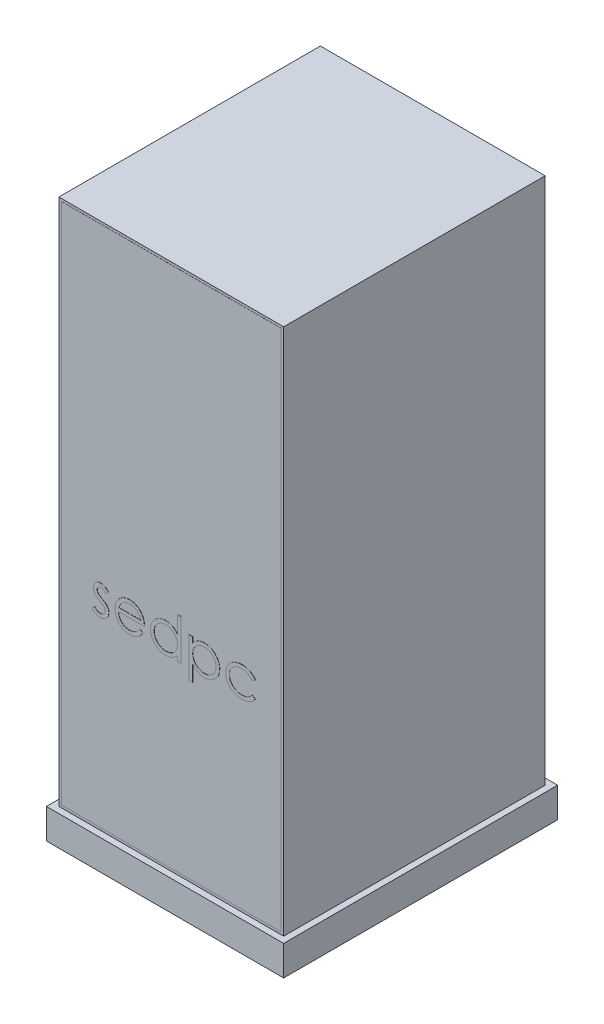
from build123d import *

# Parameters (mm, degrees)
CROQUIS1_W              = 900
CROQUIS1_H              = 2113
SALIENTE_EXTRUIR1_DEPTH = 1047
VACIADO1_T              = -10
CROQUIS9_W              = 880
CROQUIS9_H              = 2093
SALIENTE_EXTRUIR5_DEPTH = 0.3
CORTAR_EXTRUIR5_DEPTH   = 0.2
SALIENTE_EXTRUIR6_DEPTH = 1
CROQUIS15_W             = 950
CROQUIS15_H             = 1097
SALIENTE_EXTRUIR7_DEPTH = 120


with BuildPart() as part:
    # Croquis1 → Saliente-Extruir1 (new body)
    with BuildSketch(Plane.XY):
        Rectangle(CROQUIS1_W, CROQUIS1_H)
    extrude(amount=SALIENTE_EXTRUIR1_DEPTH)

    # Vaciado1
    vaciado1_openings = [part.faces().sort_by_distance(p)[0] for p in [
        (0, 0, 1047),
    ]]
    offset(amount=VACIADO1_T, openings=vaciado1_openings, kind=Kind.INTERSECTION)

    # Croquis15 → Saliente-Extruir7 (add)
    with BuildSketch(Plane.XZ.offset(1056.5)):
        with Locations((0, 523.5)):
            Rectangle(CROQUIS15_W, CROQUIS15_H)
    extrude(amount=SALIENTE_EXTRUIR7_DEPTH)


with BuildPart() as body_2:
    # Croquis9 → Saliente-Extruir5 (new body)
    with BuildSketch(Plane.XY.offset(1047)):
        Rectangle(CROQUIS9_W, CROQUIS9_H)
    extrude(amount=SALIENTE_EXTRUIR5_DEPTH)

    # Croquis10 → Cortar-Extruir5 (cut)
    with BuildSketch(Plane(origin=(0, 0, 1047), x_dir=(-1, 0, 0), z_dir=(0, 0, -1))):
        Polygon((107.980571754, 0), (-99.663574936, 0), (20.123484036, 235.750214308), align=None)
        Polygon((47.696579544, 86.228856266), (21.48645753, 63.632093208), (46.546966911, 34.564256945), (4.587154884, 63.632093208), (27.704744473, 97.00264425), (4.587154884, 113.017451669), (20.123484036, 163.685139928), align=None, mode=Mode.SUBTRACT)
    extrude(amount=-CORTAR_EXTRUIR5_DEPTH, mode=Mode.SUBTRACT)

    # Croquis14 → Saliente-Extruir6 (add)
    with BuildSketch(Plane.XY.offset(1047)):
        with BuildLine():
            Line((-250.963797924, -213.988811505), (-260.631265873, -223.942487386))
            add(Edge.make_bspline(
                [(-260.631265873, -223.942487386), (-261.465406568, -222.975783963), (-263.073531631, -221.112093568), (-265.624030948, -218.620305194), (-268.165101539, -216.527665464), (-270.66195844, -214.760902292), (-273.177387073, -213.425173142), (-275.681868717, -212.450227619), (-278.1779965, -211.846895719), (-279.846505954, -211.769133678), (-280.665821161, -211.730948924)],
                knots=[0, 0, 0, 0, 0.003829333, 0.007382504, 0.010680609, 0.013697506, 0.016542752, 0.019200362, 0.021746022, 0.024202113, 0.024202113, 0.024202113, 0.024202113], degree=3))
            add(Edge.make_bspline(
                [(-280.665821161, -211.730948924), (-281.670000629, -211.779702092), (-283.646083705, -211.875641425), (-286.477540466, -212.833286301), (-289.106015243, -214.303254081), (-291.380992551, -216.388257692), (-293.308112323, -218.781494171), (-294.714804283, -221.457398907), (-295.575047112, -224.33522089), (-295.684118887, -226.332289434), (-295.73943895, -227.345181697)],
                knots=[0, 0, 0, 0, 0.003002953, 0.005909387, 0.008871652, 0.011980015, 0.015103956, 0.018048416, 0.020996994, 0.024031604, 0.024031604, 0.024031604, 0.024031604], degree=3))
            add(Edge.make_bspline(
                [(-295.73943895, -227.345181697), (-295.689055679, -228.261942271), (-295.588431168, -230.092879083), (-294.806171075, -232.793807761), (-293.560388515, -235.427109136), (-292.396061846, -237.04014096), (-291.796129655, -237.871273444)],
                knots=[0, 0, 0, 0, 0.002746683, 0.005485624, 0.008373207, 0.011442609, 0.011442609, 0.011442609, 0.011442609], degree=3))
            add(Edge.make_bspline(
                [(-291.796129655, -237.871273444), (-291.43492833, -238.315074233), (-290.666156835, -239.259648279), (-289.223413477, -240.570644487), (-287.589535669, -242.019453728), (-285.624667064, -243.468017405), (-283.413459728, -244.99345637), (-280.907963623, -246.535695973), (-278.187691433, -248.212296673), (-276.240177883, -249.275669285), (-275.22787044, -249.828404854)],
                knots=[0, 0, 0, 0, 0.001714301, 0.003648673, 0.005835547, 0.008265143, 0.010964286, 0.013893595, 0.017089544, 0.020548977, 0.020548977, 0.020548977, 0.020548977], degree=3))
            add(Edge.make_bspline(
                [(-275.22787044, -249.828404854), (-273.993540336, -250.519870089), (-271.609221015, -251.855553237), (-268.221370501, -253.928814789), (-265.146743999, -255.98945439), (-262.359290503, -258.015434312), (-259.912644173, -260.063439379), (-257.732573392, -262.054969784), (-255.873454685, -264.050199124), (-254.832330153, -265.444165352), (-254.334691354, -266.110456136)],
                knots=[0, 0, 0, 0, 0.004244197, 0.00819839, 0.011911611, 0.015346254, 0.018530315, 0.021478207, 0.02420141, 0.026694891, 0.026694891, 0.026694891, 0.026694891], degree=3))
            add(Edge.make_bspline(
                [(-254.334691354, -266.110456136), (-253.50871386, -267.45602513), (-251.864865351, -270.133957159), (-250.138651122, -274.543507261), (-249.138060085, -279.22030505), (-248.999166525, -282.419445034), (-248.928541514, -284.046153251)],
                knots=[0, 0, 0, 0, 0.004729359, 0.009412302, 0.014127634, 0.019005727, 0.019005727, 0.019005727, 0.019005727], degree=3))
            add(Edge.make_bspline(
                [(-248.928541514, -284.046153251), (-248.961177512, -285.192289527), (-249.025490311, -287.450876265), (-249.472624062, -290.777134612), (-250.241653345, -293.958237758), (-251.289120042, -297.028702457), (-252.703554099, -299.929697218), (-254.361257755, -302.734412797), (-256.351298395, -305.382178229), (-258.623300075, -307.86951678), (-261.11093498, -310.141263181), (-263.764606255, -312.138063946), (-266.587581787, -313.796971383), (-269.55969028, -315.169720971), (-272.687684589, -316.261388385), (-275.972053782, -317.017153195), (-279.402358007, -317.469489145), (-281.735067162, -317.532285029), (-282.923683741, -317.564282258)],
                knots=[0, 0, 0, 0, 0.003438174, 0.006775297, 0.01004569, 0.013243853, 0.016486919, 0.019710123, 0.023004701, 0.026403827, 0.029802953, 0.03309753, 0.036348072, 0.039606382, 0.042905101, 0.046268336, 0.049700032, 0.053265278, 0.053265278, 0.053265278, 0.053265278], degree=3))
            add(Edge.make_bspline(
                [(-282.923683741, -317.564282258), (-284.52783777, -317.519256207), (-287.713856242, -317.42982974), (-292.425997075, -316.59044768), (-297.030688629, -315.284370882), (-301.493084921, -313.482969582), (-305.713390801, -311.208276535), (-309.57468631, -308.484017969), (-313.090384786, -305.400185944), (-315.09146363, -303.036493209), (-316.092003052, -301.854646841)],
                knots=[0, 0, 0, 0, 0.004808668, 0.009550519, 0.014311845, 0.019148298, 0.023957807, 0.028660253, 0.033300349, 0.037940445, 0.037940445, 0.037940445, 0.037940445], degree=3))
            Line((-316.092003052, -301.854646841), (-306.647141273, -291.105948924))
            add(Edge.make_bspline(
                [(-306.647141273, -291.105948924), (-305.750321113, -292.07454003), (-304.011699631, -293.952300342), (-301.231251583, -296.452582937), (-298.401900176, -298.548140591), (-295.551898321, -300.300895477), (-292.639058328, -301.651422691), (-289.679703683, -302.600230344), (-286.679853734, -303.210020491), (-284.664992574, -303.281606868), (-283.655104014, -303.317487386)],
                knots=[0, 0, 0, 0, 0.003958667, 0.007674474, 0.011198064, 0.014508564, 0.0176958, 0.02080335, 0.023815717, 0.026842821, 0.026842821, 0.026842821, 0.026842821], degree=3))
            add(Edge.make_bspline(
                [(-283.655104014, -303.317487386), (-282.279969515, -303.255310687), (-279.593187379, -303.133827847), (-275.744916899, -302.03087403), (-272.191700628, -300.301408358), (-269.106356027, -297.848280977), (-266.480079436, -294.992796077), (-264.57833724, -291.776334237), (-263.386524996, -288.293293166), (-263.246552914, -285.878828012), (-263.175336386, -284.650369998)],
                knots=[0, 0, 0, 0, 0.004117201, 0.00804432, 0.011912672, 0.015901116, 0.019796562, 0.02348889, 0.027038785, 0.030715743, 0.030715743, 0.030715743, 0.030715743], degree=3))
            add(Edge.make_bspline(
                [(-263.175336386, -284.650369998), (-263.224607593, -283.638469437), (-263.321886997, -281.640607235), (-264.085849691, -278.749073909), (-265.292932633, -276.006360106), (-266.481500612, -274.401186821), (-267.086844799, -273.583663267)],
                knots=[0, 0, 0, 0, 0.003031777, 0.005985837, 0.008917734, 0.01196083, 0.01196083, 0.01196083, 0.01196083], degree=3))
            add(Edge.make_bspline(
                [(-267.086844799, -273.583663267), (-267.450717689, -273.173845056), (-268.243364261, -272.281112979), (-269.697298419, -270.991832616), (-271.438190026, -269.602175976), (-273.485618844, -268.135707478), (-275.843712297, -266.611770737), (-278.522027788, -265.038360832), (-281.483874278, -263.340746126), (-283.578042199, -262.214997473), (-284.672732219, -261.626531857)],
                knots=[0, 0, 0, 0, 0.001642909, 0.003578849, 0.005818724, 0.00832515, 0.011130124, 0.014238813, 0.017642844, 0.02137115, 0.02137115, 0.02137115, 0.02137115], degree=3))
            add(Edge.make_bspline(
                [(-284.672732219, -261.626531857), (-285.854133392, -260.967078385), (-288.145247296, -259.688187647), (-291.390427992, -257.696279721), (-294.318111559, -255.670299762), (-296.998744762, -253.723895982), (-299.364618948, -251.754446024), (-301.406413746, -249.759763547), (-303.20451675, -247.82029275), (-304.199988639, -246.446093939), (-304.675486626, -245.789692915)],
                knots=[0, 0, 0, 0, 0.004058819, 0.007871346, 0.011417251, 0.01473736, 0.017807422, 0.020641093, 0.023297942, 0.025727538, 0.025727538, 0.025727538, 0.025727538], degree=3))
            add(Edge.make_bspline(
                [(-304.675486626, -245.789692915), (-305.497838825, -244.46773109), (-307.1428306, -241.823345469), (-308.740091057, -237.409620274), (-309.838007367, -232.763005174), (-309.936087207, -229.556851423), (-309.986233821, -227.917597562)],
                knots=[0, 0, 0, 0, 0.004658368, 0.009318364, 0.014009398, 0.018917048, 0.018917048, 0.018917048, 0.018917048], degree=3))
            add(Edge.make_bspline(
                [(-309.986233821, -227.917597562), (-309.962004248, -226.846017012), (-309.91458354, -224.748782057), (-309.5361212, -221.667271279), (-308.847068585, -218.739551444), (-307.982791739, -215.921654443), (-306.781598323, -213.268166606), (-305.346230483, -210.743702742), (-303.659515138, -208.351752175), (-301.716265874, -206.129110113), (-299.579643037, -204.110294241), (-297.271201695, -202.350499329), (-294.842859343, -200.848889665), (-292.284334599, -199.58954131), (-289.571048861, -198.636978599), (-286.721967766, -197.981232919), (-283.742858241, -197.543300507), (-281.706271456, -197.504153469), (-280.665821161, -197.484154053)],
                knots=[0, 0, 0, 0, 0.003214407, 0.00629105, 0.009291982, 0.012228703, 0.015118562, 0.01800982, 0.020930311, 0.023883002, 0.026852598, 0.02973387, 0.03257556, 0.035405838, 0.038272331, 0.04118033, 0.044166566, 0.047285648, 0.047285648, 0.047285648, 0.047285648], degree=3))
            add(Edge.make_bspline(
                [(-280.665821161, -197.484154053), (-279.432466854, -197.534243791), (-276.942621793, -197.6353629), (-273.207251255, -198.438442439), (-269.47738181, -199.759836803), (-265.743429865, -201.584837387), (-262.032748882, -203.946442114), (-258.312698597, -206.800735335), (-254.538620081, -210.128938815), (-252.182030165, -212.673439397), (-250.963797924, -213.988811505)],
                knots=[0, 0, 0, 0, 0.003697664, 0.007464693, 0.011407233, 0.015545993, 0.01990457, 0.024579408, 0.029602438, 0.034977915, 0.034977915, 0.034977915, 0.034977915], degree=3))
        make_face()
        with BuildLine():
            Line((-125.223112828, -278.894410463), (-112.566362027, -285.540794678))
            add(Edge.make_bspline(
                [(-112.566362027, -285.540794678), (-113.574950454, -287.329831489), (-115.537264124, -290.810588653), (-118.911869475, -295.59267661), (-122.449367053, -299.894698007), (-126.309439887, -303.601721612), (-130.376600325, -306.833480859), (-134.673402882, -309.66094648), (-139.222217115, -312.070250796), (-144.023258203, -314.100097596), (-149.116844987, -315.660813935), (-154.51532091, -316.763183956), (-160.229028021, -317.444596498), (-164.145444037, -317.523751098), (-166.150847203, -317.564282258)],
                knots=[0, 0, 0, 0, 0.006157639, 0.011980328, 0.017534113, 0.022841717, 0.028001894, 0.033099963, 0.038249841, 0.04342362, 0.048714622, 0.054203016, 0.059934413, 0.065948901, 0.065948901, 0.065948901, 0.065948901], degree=3))
            add(Edge.make_bspline(
                [(-166.150847203, -317.564282258), (-168.379786898, -317.512249662), (-172.727802516, -317.410749143), (-179.05692676, -316.535698078), (-185.015921809, -315.108201808), (-190.60445264, -313.114050462), (-195.808833382, -310.509311119), (-200.639407868, -307.336148909), (-205.12157922, -303.6108645), (-209.114105851, -299.301190099), (-212.708381959, -294.689187036), (-215.880017365, -289.883330847), (-218.531479416, -284.895713165), (-220.68832995, -279.758085825), (-222.430264897, -274.502830653), (-223.644326104, -269.082131946), (-224.344175387, -263.510660803), (-224.451419881, -259.741603076), (-224.505464591, -257.842226969)],
                knots=[0, 0, 0, 0, 0.006684315, 0.013039163, 0.019124775, 0.025039568, 0.030799391, 0.036541366, 0.042343524, 0.048237764, 0.054128399, 0.059870374, 0.06548978, 0.071047661, 0.076568664, 0.082077197, 0.087686155, 0.093384195, 0.093384195, 0.093384195, 0.093384195], degree=3))
            add(Edge.make_bspline(
                [(-224.505464591, -257.842226969), (-224.457424966, -256.059925733), (-224.362216774, -252.527640049), (-223.76210606, -247.299524279), (-222.698558482, -242.218233753), (-221.23913236, -237.279546292), (-219.354486551, -232.491730929), (-217.048882322, -227.851873758), (-214.318728044, -223.364912057), (-212.210860341, -220.534484206), (-211.149094398, -219.108753412)],
                knots=[0, 0, 0, 0, 0.005347184, 0.010597412, 0.015761507, 0.02090313, 0.026028994, 0.031177301, 0.036429455, 0.041760254, 0.041760254, 0.041760254, 0.041760254], degree=3))
            add(Edge.make_bspline(
                [(-211.149094398, -219.108753412), (-209.710924501, -217.391129661), (-206.88014228, -214.010292123), (-202.092407591, -209.568089489), (-196.908077257, -205.846818258), (-191.392121358, -202.762208869), (-185.480431285, -200.41843988), (-179.252474156, -198.671845972), (-172.637335066, -197.693129043), (-168.114991121, -197.554888018), (-165.801037507, -197.484154053)],
                knots=[0, 0, 0, 0, 0.006716087, 0.013219426, 0.019529878, 0.025821712, 0.032128558, 0.038563111, 0.045187853, 0.052129265, 0.052129265, 0.052129265, 0.052129265], degree=3))
            add(Edge.make_bspline(
                [(-165.801037507, -197.484154053), (-163.422163981, -197.545569842), (-158.755356397, -197.66605362), (-151.95032805, -198.783033742), (-145.51139555, -200.554346039), (-139.441135533, -203.055964393), (-133.738932563, -206.28355835), (-128.441851029, -210.281420445), (-123.459300281, -214.926812259), (-120.560589741, -218.499286401), (-119.085542716, -220.317186905)],
                knots=[0, 0, 0, 0, 0.007131981, 0.013991322, 0.020626741, 0.027128836, 0.033637149, 0.040226304, 0.046997801, 0.054013698, 0.054013698, 0.054013698, 0.054013698], degree=3))
            add(Edge.make_bspline(
                [(-119.085542716, -220.317186905), (-118.081928014, -221.687135061), (-116.08137897, -224.417912587), (-113.575528361, -228.870675784), (-111.400317946, -233.529334885), (-109.661644357, -238.469194789), (-108.253781267, -243.631725747), (-107.235204131, -249.053834025), (-106.63786786, -254.733905004), (-106.520451944, -258.604073771), (-106.460592796, -260.577102771)],
                knots=[0, 0, 0, 0, 0.005090625, 0.010147365, 0.015298028, 0.020498323, 0.025836705, 0.031337798, 0.037030511, 0.042950944, 0.042950944, 0.042950944, 0.042950944], degree=3))
            Line((-106.460592796, -260.577102771), (-210.258669719, -260.577102771))
            add(Edge.make_bspline(
                [(-210.258669719, -260.577102771), (-210.18883757, -262.105659542), (-210.051515466, -265.111504783), (-209.411292901, -269.509822445), (-208.402152091, -273.699613321), (-206.983876749, -277.649451296), (-205.26634484, -281.410924937), (-203.162421257, -284.956131614), (-200.652377203, -288.268923441), (-197.852675838, -291.378932897), (-194.736318299, -294.148474564), (-191.457779407, -296.627322986), (-187.970106995, -298.70493398), (-184.300801066, -300.391307551), (-180.455795096, -301.711486887), (-176.433877675, -302.612634468), (-172.242963112, -303.216206815), (-169.386110175, -303.283320201), (-167.931696562, -303.317487386)],
                knots=[0, 0, 0, 0, 0.004588262, 0.009022633, 0.013311038, 0.017495241, 0.021593115, 0.025699864, 0.029833978, 0.034043843, 0.038232395, 0.042321993, 0.046357824, 0.050384625, 0.054417323, 0.058528993, 0.062734051, 0.067094948, 0.067094948, 0.067094948, 0.067094948], degree=3))
            add(Edge.make_bspline(
                [(-167.931696562, -303.317487386), (-166.509698081, -303.289907673), (-163.688180314, -303.235184232), (-159.486255713, -302.703058273), (-155.352427149, -301.842620772), (-151.303803979, -300.668324793), (-147.422554897, -299.236089001), (-143.828203162, -297.507852243), (-140.52256481, -295.596060159), (-137.432973826, -293.409407041), (-134.436182342, -290.732964273), (-131.463362422, -287.393058357), (-128.275814216, -283.443016918), (-126.280571974, -280.470052783), (-125.223112828, -278.894410463)],
                knots=[0, 0, 0, 0, 0.004264284, 0.008461157, 0.012683495, 0.016920656, 0.021096755, 0.02507949, 0.028870203, 0.032541105, 0.036415335, 0.040894746, 0.045940675, 0.051630545, 0.051630545, 0.051630545, 0.051630545], degree=3))
        make_face()
        with BuildLine():
            add(Edge.make_bspline(
                [(-120.707387668, -246.330307899), (-121.22884171, -244.440598983), (-122.232472884, -240.803517622), (-124.329622272, -235.767020091), (-126.691438582, -231.290818866), (-129.486424255, -227.409171224), (-132.653202167, -223.961869028), (-136.311037237, -220.949311772), (-140.412950978, -218.254305956), (-144.937740573, -215.979531873), (-149.72935011, -214.043241852), (-154.746130961, -212.744888388), (-159.865037768, -211.855455577), (-163.327342898, -211.772628516), (-165.069617235, -211.730948924)],
                knots=[0, 0, 0, 0, 0.005875681, 0.011308794, 0.016331522, 0.021026435, 0.025617231, 0.030336315, 0.03520507, 0.04031087, 0.045507566, 0.050675869, 0.055830752, 0.061052298, 0.061052298, 0.061052298, 0.061052298], degree=3))
            add(Edge.make_bspline(
                [(-165.069617235, -211.730948924), (-166.491538196, -211.758692598), (-169.302376993, -211.813536008), (-173.443532586, -212.333788303), (-177.420433215, -213.193752695), (-181.262423046, -214.371448941), (-184.91915529, -215.941196269), (-188.465846563, -217.781935476), (-191.812314535, -220.02900017), (-193.905151866, -221.741633942), (-194.962445761, -222.606850367)],
                knots=[0, 0, 0, 0, 0.004264284, 0.008429592, 0.012496377, 0.016459384, 0.020463897, 0.024418474, 0.028431564, 0.032528944, 0.032528944, 0.032528944, 0.032528944], degree=3))
            add(Edge.make_bspline(
                [(-194.962445761, -222.606850367), (-195.719605335, -223.291485397), (-197.251911781, -224.677019839), (-199.299356863, -227.064130279), (-201.259714017, -229.638218992), (-203.043776124, -232.497765714), (-204.680152367, -235.610208191), (-206.211408474, -238.949293789), (-207.589649308, -242.540360769), (-208.365080013, -245.042824977), (-208.764028293, -246.330307899)],
                knots=[0, 0, 0, 0, 0.003059503, 0.006191688, 0.009416303, 0.012760238, 0.016288273, 0.019959726, 0.023774904, 0.027817746, 0.027817746, 0.027817746, 0.027817746], degree=3))
            Line((-208.764028293, -246.330307899), (-120.707387668, -246.330307899))
        make_face(mode=Mode.SUBTRACT)
        with BuildLine():
            Line((40.077868743, -152.708513027), (40.077868743, -315.529025848))
            Line((40.077868743, -315.529025848), (25.831073871, -315.529025848))
            Line((25.831073871, -315.529025848), (25.831073871, -295.462669678))
            add(Edge.make_bspline(
                [(25.831073871, -295.462669678), (24.224578725, -297.278751261), (21.089483246, -300.822857306), (15.853403966, -305.453012987), (10.30313304, -309.280172571), (4.465608832, -312.371258034), (-1.653897206, -314.693183446), (-8.041819736, -316.343555663), (-14.700764511, -317.404633187), (-19.247924889, -317.510588465), (-21.55223943, -317.564282258)],
                knots=[0, 0, 0, 0, 0.007269058, 0.014185659, 0.020907315, 0.027450882, 0.033953366, 0.040494228, 0.047218065, 0.05412618, 0.05412618, 0.05412618, 0.05412618], degree=3))
            add(Edge.make_bspline(
                [(-21.55223943, -317.564282258), (-23.600928765, -317.508657516), (-27.641034844, -317.398963061), (-33.584139414, -316.547958575), (-39.303323586, -315.181319665), (-44.803991703, -313.280815035), (-50.050549728, -310.759827768), (-55.087918398, -307.741706874), (-59.890001215, -304.147569224), (-64.383603161, -300.038755081), (-68.521626035, -295.575839591), (-72.152976615, -290.815809429), (-75.180705594, -285.779247788), (-77.712544969, -280.529922594), (-79.662736306, -275.027424458), (-81.022254717, -269.290781484), (-81.872267835, -263.326776505), (-81.981916945, -259.265519565), (-82.037515873, -257.206209341)],
                knots=[0, 0, 0, 0, 0.00614424, 0.012116713, 0.017971012, 0.023764012, 0.029539178, 0.035402023, 0.041355161, 0.047500964, 0.053644793, 0.059591642, 0.065427256, 0.071244818, 0.07704837, 0.08290267, 0.088906639, 0.095082646, 0.095082646, 0.095082646, 0.095082646], degree=3))
            add(Edge.make_bspline(
                [(-82.037515873, -257.206209341), (-81.980684671, -255.189462786), (-81.86833245, -251.202463643), (-81.031347121, -245.33875127), (-79.623869229, -239.69095873), (-77.648663281, -234.277268805), (-75.115831752, -229.091130816), (-72.034807805, -224.128876824), (-68.405368935, -219.376836296), (-64.221063331, -214.946748509), (-59.688307684, -210.854599219), (-54.839233104, -207.298188943), (-49.794462844, -204.226746158), (-44.475747724, -201.793177768), (-38.961811184, -199.824264812), (-33.203565609, -198.462055187), (-27.224969005, -197.65935526), (-23.165935972, -197.5431156), (-21.107027091, -197.484154053)],
                knots=[0, 0, 0, 0, 0.006048942, 0.011958433, 0.017727642, 0.023482108, 0.02921377, 0.035011743, 0.040977863, 0.047120045, 0.053268152, 0.059272374, 0.065135218, 0.070954431, 0.076787965, 0.08267319, 0.088672863, 0.094848869, 0.094848869, 0.094848869, 0.094848869], degree=3))
            add(Edge.make_bspline(
                [(-21.107027091, -197.484154053), (-18.738621883, -197.555233051), (-14.089705664, -197.694753227), (-7.290737009, -198.860720587), (-0.859656103, -200.818465402), (5.240561543, -203.49867709), (10.973548382, -206.982139738), (16.381328151, -211.189080408), (21.36985744, -216.238561677), (24.321329391, -220.030943759), (25.831073871, -221.970832739)],
                knots=[0, 0, 0, 0, 0.007101857, 0.013940155, 0.020620006, 0.027226328, 0.033874538, 0.040693955, 0.047732303, 0.055102702, 0.055102702, 0.055102702, 0.055102702], degree=3))
            Line((25.831073871, -221.970832739), (25.831073871, -152.708513027))
            Line((25.831073871, -152.708513027), (40.077868743, -152.708513027))
        make_face()
        with BuildLine():
            add(Edge.make_bspline(
                [(-20.916221802, -211.730948924), (-22.998764984, -211.805046064), (-27.109373983, -211.951302033), (-33.143869791, -213.09309985), (-38.918442501, -214.99286538), (-44.40421087, -217.591008755), (-49.514519267, -220.858026451), (-54.081696479, -224.809603479), (-58.143097576, -229.337925193), (-61.558865276, -234.422556628), (-64.343362814, -239.873491473), (-66.301296049, -245.571457058), (-67.59257977, -251.413682826), (-67.724501953, -255.376204645), (-67.790721001, -257.365213748)],
                knots=[0, 0, 0, 0, 0.006244644, 0.012325934, 0.018349746, 0.024438016, 0.030489298, 0.036487623, 0.042501017, 0.048683979, 0.054813635, 0.060807742, 0.066720312, 0.072679308, 0.072679308, 0.072679308, 0.072679308], degree=3))
            add(Edge.make_bspline(
                [(-67.790721001, -257.365213748), (-67.706134769, -259.342336467), (-67.537293854, -263.288832251), (-66.323958786, -269.139022697), (-64.288335956, -274.838331033), (-61.510570968, -280.33838324), (-58.032284774, -285.444876363), (-54.000549462, -290.059517637), (-49.376375988, -294.02779539), (-44.254306918, -297.349642479), (-38.783873974, -300.033085391), (-33.031049226, -301.900241183), (-27.103975638, -303.105733375), (-23.073887638, -303.246543575), (-21.043425328, -303.317487386)],
                knots=[0, 0, 0, 0, 0.005929394, 0.011835546, 0.017840189, 0.024040953, 0.030268082, 0.03632905, 0.042372221, 0.048484778, 0.054600559, 0.060594161, 0.066587678, 0.072673622, 0.072673622, 0.072673622, 0.072673622], degree=3))
            add(Edge.make_bspline(
                [(-21.043425328, -303.317487386), (-18.98210181, -303.242196165), (-14.882333778, -303.092449394), (-8.829935242, -301.945763433), (-2.956413715, -300.051250079), (2.658221286, -297.425111116), (7.88863152, -294.170402474), (12.582999541, -290.360080845), (16.552473821, -285.928543565), (19.917638612, -281.058254445), (22.556309298, -275.719174605), (24.478366269, -270.034373811), (25.614739852, -264.003654163), (25.757965447, -259.882326047), (25.831073871, -257.778625206)],
                knots=[0, 0, 0, 0, 0.006181162, 0.012293718, 0.01840826, 0.024653956, 0.030839534, 0.03684948, 0.042725763, 0.048626862, 0.054557364, 0.060530853, 0.066580882, 0.07288901, 0.07288901, 0.07288901, 0.07288901], degree=3))
            add(Edge.make_bspline(
                [(25.831073871, -257.778625206), (25.7875466, -256.17580218), (25.701871156, -253.020939238), (25.047341752, -248.388726834), (24.006171875, -243.955804261), (22.539042021, -239.717510865), (20.611758764, -235.697279809), (18.287306525, -231.866244971), (15.524809341, -228.244331454), (12.368737053, -224.881413592), (8.914101081, -221.814070483), (5.258562988, -219.076120993), (1.358812679, -216.826915944), (-2.719567209, -214.965401129), (-6.983652737, -213.484075402), (-11.468141564, -212.495847863), (-16.125367043, -211.817290445), (-19.302455984, -211.76003246), (-20.916221802, -211.730948924)],
                knots=[0, 0, 0, 0, 0.00480709, 0.009461874, 0.014005062, 0.018450366, 0.022888383, 0.027355134, 0.031870971, 0.036528362, 0.041168458, 0.045716095, 0.050204979, 0.054644933, 0.059150345, 0.063717288, 0.068403577, 0.073241075, 0.073241075, 0.073241075, 0.073241075], degree=3))
        make_face(mode=Mode.SUBTRACT)
        with BuildLine():
            Line((72.641971307, -199.519410463), (86.888766179, -199.519410463))
            Line((86.888766179, -199.519410463), (86.888766179, -220.985005415))
            add(Edge.make_bspline(
                [(86.888766179, -220.985005415), (88.401766348, -219.037472488), (91.341979393, -215.252831988), (96.409501864, -210.354708299), (101.758324983, -206.223792741), (107.52609405, -202.986084995), (113.623168561, -200.54492674), (120.024527245, -198.740644549), (126.784499795, -197.677406236), (131.406231756, -197.549423747), (133.763265377, -197.484154053)],
                knots=[0, 0, 0, 0, 0.007390473, 0.014361905, 0.021078444, 0.027614434, 0.034133925, 0.040738716, 0.047530271, 0.054598728, 0.054598728, 0.054598728, 0.054598728], degree=3))
            add(Edge.make_bspline(
                [(133.763265377, -197.484154053), (135.822098808, -197.543716095), (139.891491241, -197.661443601), (145.881501982, -198.458507148), (151.649814021, -199.824559626), (157.163793612, -201.793101144), (162.482511211, -204.226759959), (167.527227882, -207.298211216), (172.376521298, -210.854492012), (176.908434161, -214.947164568), (181.095867617, -219.375303794), (184.71746226, -224.138815446), (187.841295063, -229.081047044), (190.366340653, -234.278616941), (192.344290696, -239.690596294), (193.751027861, -245.338850578), (194.588213833, -251.202437877), (194.700538605, -255.189454131), (194.757355922, -257.206209341)],
                knots=[0, 0, 0, 0, 0.006176006, 0.012207201, 0.018092426, 0.02392596, 0.029745173, 0.035608018, 0.04161224, 0.047760346, 0.053902528, 0.059868648, 0.065683429, 0.071415091, 0.077169557, 0.082938766, 0.088848256, 0.094897199, 0.094897199, 0.094897199, 0.094897199], degree=3))
            add(Edge.make_bspline(
                [(194.757355922, -257.206209341), (194.701771399, -259.265528336), (194.592150697, -263.326802575), (193.741930784, -269.290681629), (192.383172565, -275.027787513), (190.430176402, -280.528577682), (187.906437466, -285.789264723), (184.835552049, -290.80605483), (181.212130148, -295.577340651), (177.070971855, -300.038347191), (172.578213684, -304.147673169), (167.775913268, -307.741685612), (162.738597716, -310.759812277), (157.492038707, -313.280896515), (151.991322246, -315.181006292), (146.262112865, -316.551599392), (140.307529792, -317.396806877), (136.257084683, -317.508029052), (134.208477717, -317.564282258)],
                knots=[0, 0, 0, 0, 0.006176006, 0.012179976, 0.018034275, 0.023837827, 0.02965539, 0.03550753, 0.041454379, 0.047598208, 0.053744011, 0.059697149, 0.065559994, 0.07133516, 0.07712816, 0.082982459, 0.088986429, 0.095130668, 0.095130668, 0.095130668, 0.095130668], degree=3))
            add(Edge.make_bspline(
                [(134.208477717, -317.564282258), (131.903084275, -317.505553479), (127.34925634, -317.389546924), (120.690933432, -316.213916539), (114.283019077, -314.456919815), (108.19650667, -311.885215461), (102.383180887, -308.607911706), (96.875925412, -304.611484506), (91.645486976, -299.904291884), (88.497304057, -296.333241651), (86.888766179, -294.508643235)],
                knots=[0, 0, 0, 0, 0.006909652, 0.013648588, 0.020222762, 0.026808002, 0.033415013, 0.040202397, 0.047182527, 0.05447499, 0.05447499, 0.05447499, 0.05447499], degree=3))
            Line((86.888766179, -294.508643235), (86.888766179, -358.269410463))
            Line((86.888766179, -358.269410463), (72.641971307, -358.269410463))
            Line((72.641971307, -358.269410463), (72.641971307, -199.519410463))
        make_face()
        with BuildLine():
            add(Edge.make_bspline(
                [(133.636061852, -211.730948924), (132.022274553, -211.759989208), (128.845143322, -211.81716204), (124.188224819, -212.496337574), (119.702610774, -213.482299407), (115.433507978, -214.975089168), (111.339997873, -216.807463909), (107.453608971, -219.097183702), (103.7770693, -221.802828253), (100.319628993, -224.872569923), (97.196186754, -228.255064706), (94.431082521, -231.864940334), (92.108465468, -235.697625238), (90.180695264, -239.717418466), (88.713696371, -243.955829614), (87.672490509, -248.388719832), (87.017970936, -253.020941074), (86.932294138, -256.175802798), (86.888766179, -257.778625206)],
                knots=[0, 0, 0, 0, 0.004837498, 0.009523787, 0.014090731, 0.018596142, 0.023065043, 0.02752647, 0.03209972, 0.036739816, 0.041375551, 0.045891388, 0.050358139, 0.054796157, 0.05924146, 0.063784648, 0.068439432, 0.073246522, 0.073246522, 0.073246522, 0.073246522], degree=3))
            add(Edge.make_bspline(
                [(86.888766179, -257.778625206), (86.960922866, -259.882657454), (87.102283928, -264.004634822), (88.251514547, -270.027343209), (90.121828308, -275.726543299), (92.776523536, -281.054240333), (96.130574225, -285.952033213), (100.171812034, -290.337642864), (104.863670599, -294.183501814), (110.128146793, -297.422965822), (115.771579147, -300.053138831), (121.658297302, -301.936104805), (127.707347256, -303.095988019), (131.797124616, -303.243254457), (133.858668021, -303.317487386)],
                knots=[0, 0, 0, 0, 0.006308128, 0.012358157, 0.018321564, 0.024252066, 0.030153165, 0.036072316, 0.042082262, 0.048294839, 0.054569372, 0.060714187, 0.066795477, 0.072976639, 0.072976639, 0.072976639, 0.072976639], degree=3))
            add(Edge.make_bspline(
                [(133.858668021, -303.317487386), (135.878683211, -303.246894577), (139.888050213, -303.106780543), (145.791650723, -301.894012748), (151.52890468, -300.041399135), (156.979933931, -297.339947825), (162.097284984, -294.029327336), (166.718341164, -290.057854404), (170.755440456, -285.454560551), (174.196430847, -280.328817742), (176.969180359, -274.832648555), (179.052444812, -269.145707001), (180.254797956, -263.288039596), (180.42519515, -259.342071903), (180.51056105, -257.365213748)],
                knots=[0, 0, 0, 0, 0.006054206, 0.012016511, 0.018010113, 0.024097303, 0.030209859, 0.036253031, 0.042313999, 0.048523319, 0.054724083, 0.060739412, 0.066645564, 0.072574957, 0.072574957, 0.072574957, 0.072574957], degree=3))
            add(Edge.make_bspline(
                [(180.51056105, -257.365213748), (180.44457848, -255.376076741), (180.31312741, -251.413300111), (179.018315342, -245.572982725), (177.072494925, -239.86306381), (174.234995068, -234.441953161), (170.86943749, -229.326842984), (166.798770128, -224.811363473), (162.235106932, -220.857550816), (157.123848423, -217.591137583), (151.638336269, -214.992831204), (145.86369544, -213.093109012), (139.82921776, -211.951299661), (135.718606287, -211.805045267), (133.636061852, -211.730948924)],
                knots=[0, 0, 0, 0, 0.005958996, 0.011871566, 0.017865674, 0.024009749, 0.030174939, 0.036188333, 0.042186657, 0.04823794, 0.05432621, 0.060350022, 0.066431312, 0.072675956, 0.072675956, 0.072675956, 0.072675956], degree=3))
        make_face(mode=Mode.SUBTRACT)
        with BuildLine():
            Line((337.22530464, -224.673907658), (325.299974111, -232.083513027))
            add(Edge.make_bspline(
                [(325.299974111, -232.083513027), (323.992333789, -230.458439449), (321.418465826, -227.259758018), (316.949007606, -223.131807473), (312.18598989, -219.586373793), (307.048021297, -216.69695366), (301.542308223, -214.464409304), (295.690563184, -212.884610697), (289.49362064, -211.900168255), (285.245234827, -211.788279583), (283.068403598, -211.730948924)],
                knots=[0, 0, 0, 0, 0.006250228, 0.012302513, 0.018192205, 0.024030071, 0.029935453, 0.035968324, 0.042179598, 0.048706531, 0.048706531, 0.048706531, 0.048706531], degree=3))
            add(Edge.make_bspline(
                [(283.068403598, -211.730948924), (281.32855091, -211.778884268), (277.901958347, -211.873291622), (272.871572102, -212.463410428), (268.079936799, -213.535744376), (263.497018931, -214.948662769), (259.155414233, -216.842336634), (255.043747575, -219.146922001), (251.125548564, -221.825263115), (247.514360654, -224.928169996), (244.211044975, -228.302680993), (241.349058517, -231.920080746), (238.85727619, -235.672018669), (236.90211317, -239.652186977), (235.302132224, -243.769529393), (234.249541701, -248.10176499), (233.548107302, -252.593392476), (233.467855611, -255.655831457), (233.427227717, -257.206209341)],
                knots=[0, 0, 0, 0, 0.005220093, 0.010280831, 0.015165037, 0.019932412, 0.024646779, 0.029344814, 0.034055211, 0.038860092, 0.043605248, 0.048199237, 0.052680003, 0.057088756, 0.061477048, 0.065904228, 0.070437611, 0.075085873, 0.075085873, 0.075085873, 0.075085873], degree=3))
            add(Edge.make_bspline(
                [(233.427227717, -257.206209341), (233.507929514, -259.236812841), (233.668245721, -263.270659222), (234.924704786, -269.225058838), (236.981397546, -274.981954794), (239.796164344, -280.50047387), (243.35566294, -285.607423056), (247.536347061, -290.187744023), (252.340534052, -294.152685303), (257.72589334, -297.439831976), (263.565976703, -300.08240115), (269.797599311, -301.965055177), (276.369839353, -303.101359218), (280.869573953, -303.244503777), (283.163806243, -303.317487386)],
                knots=[0, 0, 0, 0, 0.006088021, 0.012094011, 0.018169228, 0.024384409, 0.030621356, 0.036788596, 0.042932835, 0.049243287, 0.05566242, 0.062110788, 0.068724301, 0.075603884, 0.075603884, 0.075603884, 0.075603884], degree=3))
            add(Edge.make_bspline(
                [(283.163806243, -303.317487386), (285.266344963, -303.258545906), (289.398391491, -303.142710257), (295.438479064, -302.166217992), (301.188853591, -300.567667467), (306.649310693, -298.338470483), (311.80987251, -295.457043869), (316.637195801, -291.902895764), (321.227335859, -287.778271392), (323.925948725, -284.588849123), (325.299974111, -282.964923283)],
                knots=[0, 0, 0, 0, 0.0063046, 0.012390212, 0.018300472, 0.024176411, 0.030042015, 0.035982995, 0.042128798, 0.048503982, 0.048503982, 0.048503982, 0.048503982], degree=3))
            Line((325.299974111, -282.964923283), (337.22530464, -290.78794011))
            add(Edge.make_bspline(
                [(337.22530464, -290.78794011), (336.518291004, -291.826198081), (335.106610399, -293.899267914), (332.746785958, -296.82226892), (330.201350735, -299.558288081), (327.480235269, -302.103657919), (324.61897018, -304.519289505), (321.519811423, -306.689700206), (318.282689761, -308.736886808), (314.869602964, -310.578970654), (311.315839161, -312.234793096), (307.626398918, -313.658606911), (303.817314556, -314.881893857), (299.884107493, -315.854230657), (295.819023534, -316.630329402), (291.63257583, -317.145300866), (287.326206236, -317.529715403), (284.415540801, -317.55266008), (282.941200073, -317.564282258)],
                knots=[0, 0, 0, 0, 0.003767163, 0.007521822, 0.011257039, 0.014969034, 0.018694626, 0.022480134, 0.026309467, 0.03017991, 0.034106771, 0.038063522, 0.042036087, 0.046100757, 0.050210952, 0.054443338, 0.058750684, 0.063172036, 0.063172036, 0.063172036, 0.063172036], degree=3))
            add(Edge.make_bspline(
                [(282.941200073, -317.564282258), (280.690992134, -317.523856353), (276.280568243, -317.444621285), (269.825225933, -316.573379722), (263.656034599, -315.259944984), (257.775101934, -313.374732767), (252.181512381, -310.947909032), (246.88048166, -307.98350612), (241.889562264, -304.456907078), (237.258108902, -300.430881468), (233.004450452, -296.065680967), (229.352012532, -291.355345403), (226.184030615, -286.473055019), (223.640059912, -281.310980088), (221.615002891, -275.937729261), (220.231390842, -270.310257664), (219.33650631, -264.474958998), (219.232938739, -260.495646133), (219.180432845, -258.478244598)],
                knots=[0, 0, 0, 0, 0.006746585, 0.013223356, 0.019504574, 0.025649389, 0.031716694, 0.037767642, 0.043837863, 0.050015589, 0.056155465, 0.06209074, 0.067868795, 0.073585971, 0.079321601, 0.085059965, 0.090942526, 0.096991468, 0.096991468, 0.096991468, 0.096991468], degree=3))
            add(Edge.make_bspline(
                [(219.180432845, -258.478244598), (219.200436077, -257.10943703), (219.240225807, -254.386652855), (219.696606101, -250.345555187), (220.286179695, -246.358274739), (221.285204197, -242.475353182), (222.439118563, -238.637898954), (223.912115897, -234.892165431), (225.640014167, -231.220746342), (227.601798919, -227.633099321), (229.810181287, -224.188245208), (232.25408008, -220.933703989), (234.841448188, -217.830378912), (237.693328983, -214.985408339), (240.688698997, -212.285016806), (243.912302609, -209.801344738), (247.345650166, -207.527092647), (250.937179441, -205.420207304), (254.684800276, -203.544261499), (258.565859967, -201.928039639), (262.556972364, -200.546797804), (266.664521762, -199.45328611), (270.861244615, -198.536281551), (275.180212443, -197.959436379), (279.604902524, -197.551844714), (282.601014983, -197.506905212), (284.117832685, -197.484154053)],
                knots=[0, 0, 0, 0, 0.004104285, 0.008164101, 0.012189771, 0.016185055, 0.020178441, 0.024205995, 0.028246209, 0.03234507, 0.036464604, 0.040509696, 0.044548908, 0.048574076, 0.052583006, 0.056641202, 0.060768951, 0.064930495, 0.069125922, 0.07333098, 0.077534715, 0.08178534, 0.086076456, 0.090411886, 0.09484865, 0.099397955, 0.099397955, 0.099397955, 0.099397955], degree=3))
            add(Edge.make_bspline(
                [(284.117832685, -197.484154053), (286.017394728, -197.525968397), (289.807023913, -197.609388079), (295.428620251, -198.311455519), (300.967416544, -199.369928692), (306.326231595, -200.938053471), (311.440091357, -202.836869284), (316.226877848, -204.969231686), (320.573911131, -207.445486912), (324.562055352, -210.154220673), (328.198769175, -213.209518896), (331.52138366, -216.647905893), (334.598033463, -220.451486908), (336.342320018, -223.254818292), (337.22530464, -224.673907658)],
                knots=[0, 0, 0, 0, 0.005696709, 0.011364943, 0.016971737, 0.022597977, 0.028091711, 0.033329115, 0.038299115, 0.043079942, 0.047774639, 0.052519796, 0.057406795, 0.062416822, 0.062416822, 0.062416822, 0.062416822], degree=3))
        make_face()
    extrude(amount=SALIENTE_EXTRUIR6_DEPTH)


solid = Compound([part.part, body_2.part])
